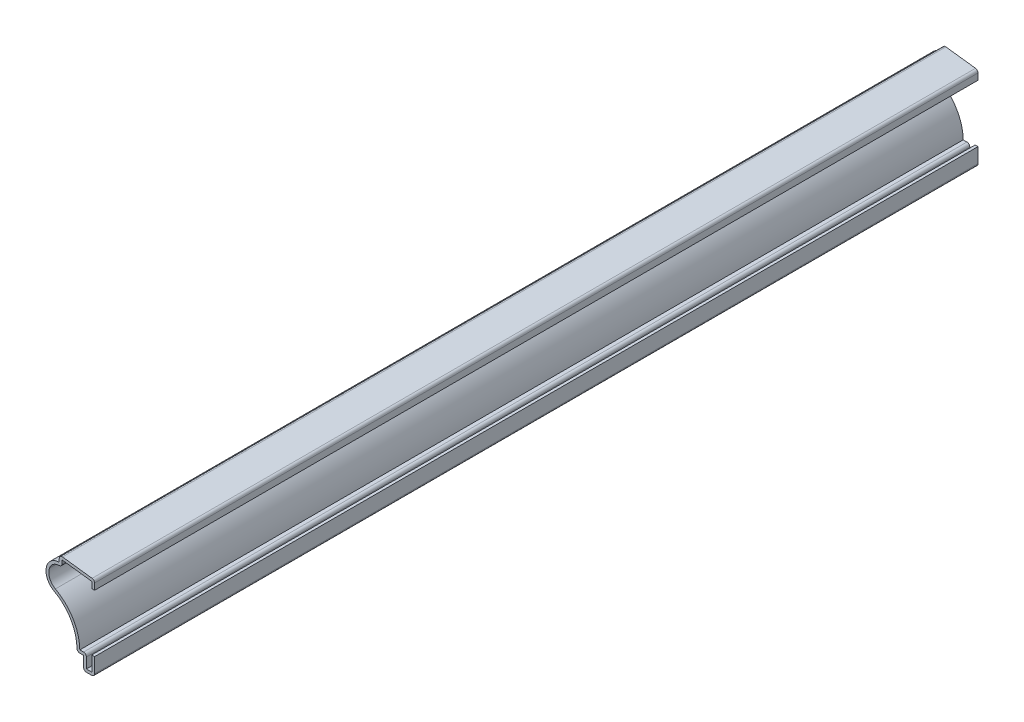
from build123d import *

# Parameters (mm, degrees)
EXTRUDE_THIN1_DEPTH = 317.5
FILLET1_R           = 1.016


with BuildPart() as part:
    # Sketch1 → Extrude-Thin1 (new body)
    with BuildSketch(Plane.XY):
        with BuildLine():
            Line((0, 6.35), (0, 0))
            Line((0, 0), (-3.96875, 0))
            Line((-3.96875, 0), (-3.96875, 4.7625))
            Line((-3.96875, 4.7625), (-6.35, 4.7625))
            ThreePointArc((-6.35, 4.7625), (-8.34834139, 13.302516912), (-14.576333586, 19.478063073))
            ThreePointArc((-14.576333586, 19.478063073), (-17.085021571, 22.337680243), (-17.166208015, 26.140880807))
            ThreePointArc((-17.166208015, 26.140880807), (-15.447363075, 28.466364673), (-12.7, 29.36875))
            Line((-12.7, 29.36875), (-12.7, 31.75))
            Line((-12.7, 31.75), (0, 30.1625))
            Line((0, 30.1625), (0, 26.9875))
            Line((0, 26.9875), (-1.016, 26.9875))
            Line((-1.016, 26.9875), (-1.016, 29.265593266))
            Line((-1.016, 29.265593266), (-11.684, 30.599093266))
            Line((-11.684, 30.599093266), (-11.684, 28.224203151))
            ThreePointArc((-11.684, 28.224203151), (-14.420615811, 27.912235037), (-16.204387121, 25.813533029))
            ThreePointArc((-16.204387121, 25.813533029), (-16.138046198, 22.705774854), (-14.08808973, 20.369059109))
            ThreePointArc((-14.08808973, 20.369059109), (-7.729180549, 14.259833631), (-5.315606066, 5.7785))
            Line((-5.315606066, 5.7785), (-2.95275, 5.7785))
            Line((-2.95275, 5.7785), (-2.95275, 1.016))
            Line((-2.95275, 1.016), (-1.016, 1.016))
            Line((-1.016, 1.016), (-1.016, 6.35))
            Line((-1.016, 6.35), (0, 6.35))
        make_face()
    extrude(amount=-EXTRUDE_THIN1_DEPTH)

    # Fillet1
    fillet1_edges = [part.edges().sort_by_distance(p)[0] for p in [
        (-11.684, 28.224203151, -158.75),
        (-2.95275, 5.7785, -158.75),
        (0, 0, -158.75),
        (-3.96875, 0, -158.75),
        (-6.35, 4.7625, -158.75),
        (-12.7, 31.75, -158.75),
        (0, 30.1625, -158.75),
    ]]
    fillet(fillet1_edges, radius=FILLET1_R)


solid = part.part
